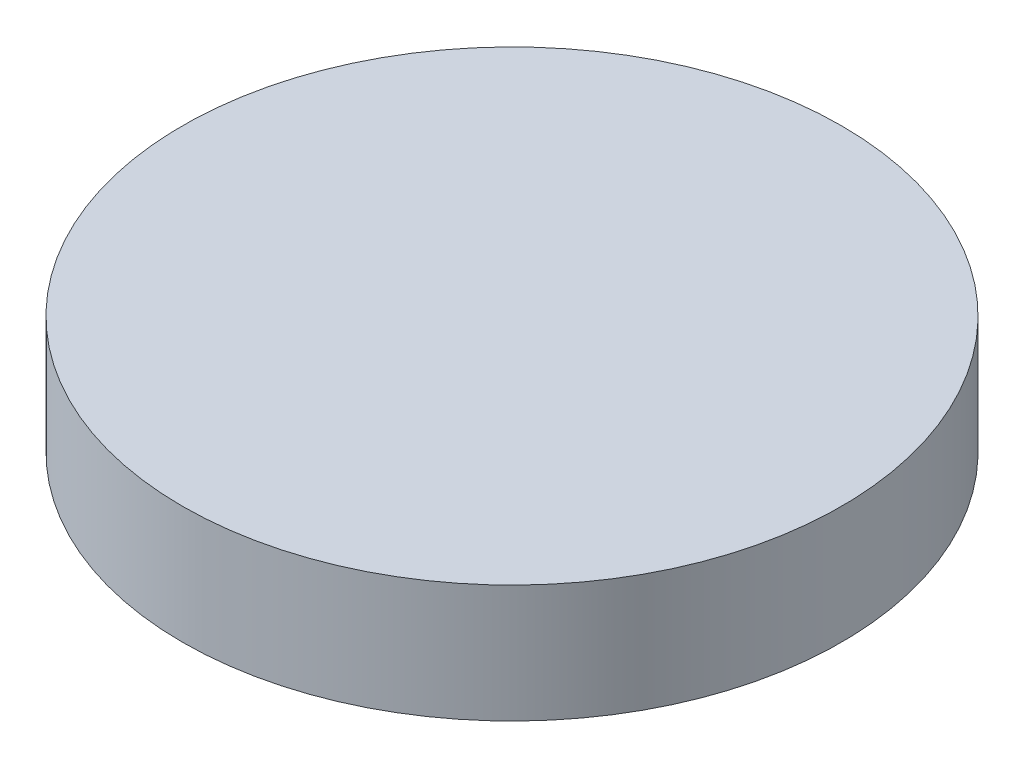
from build123d import *

# Parameters (mm, degrees)
IZIM1_R                     = 27.985
Y_KSEKLIK_EKSTR_ZYON1_DEPTH = 10


with BuildPart() as part:
    # Çizim1 → Yükseklik-Ekstrüzyon1 (new body)
    with BuildSketch(Plane(origin=(0, 0, 0), x_dir=(1, 0, 0), z_dir=(0, 1, 0))):
        Circle(IZIM1_R)
    extrude(amount=Y_KSEKLIK_EKSTR_ZYON1_DEPTH)


solid = part.part
